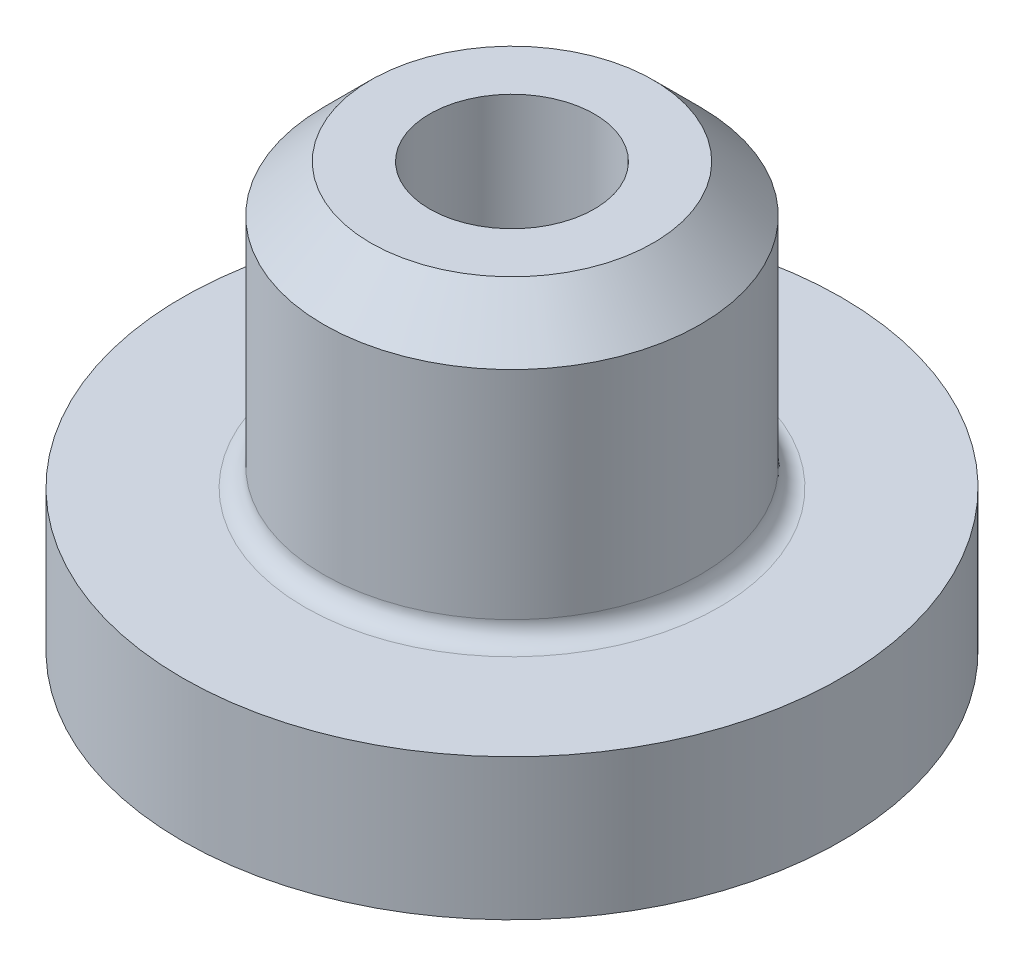
from build123d import *

# Parameters (mm, degrees)
SKETCH3_R          = 0.875
CUT_EXTRUDE1_DEPTH = 2
CHAMFER1_SIZE      = 0.5
FILLET1_R          = 0.2
FILLET2_R          = 0.2


with BuildPart() as part:
    # Sketch2 → Revolve1 (revolve)
    with BuildSketch(Plane.XY):
        Polygon((0, 2), (0, 4.5), (2, 4.5), (2, 1.5), (3.5, 1.5), (3.5, 0), (1.2, 0), (1.2, 2), align=None)
    revolve(axis=Axis((0, 2, 0), (0, 1, 0)))

    # Sketch3 → Cut-Extrude1 (cut)
    with BuildSketch(Plane(origin=(0, 4.5, 0), x_dir=(1, 0, 0), z_dir=(0, 1, 0))):
        Circle(SKETCH3_R)
    extrude(amount=-CUT_EXTRUDE1_DEPTH, mode=Mode.SUBTRACT)

    # Chamfer1
    chamfer1_edges = [part.edges().sort_by_distance(p)[0] for p in [
        (-2, 4.5, 0),
    ]]
    chamfer(chamfer1_edges, length=CHAMFER1_SIZE)

    # Fillet1
    fillet1_edges = [part.edges().sort_by_distance(p)[0] for p in [
        (-2, 1.5, 0),
    ]]
    fillet(fillet1_edges, radius=FILLET1_R)

    # Fillet2
    fillet2_edges = [part.edges().sort_by_distance(p)[0] for p in [
        (-0.875, 2.5, 0),
        (-1.2, 2, 0),
    ]]
    fillet(fillet2_edges, radius=FILLET2_R)


solid = part.part
